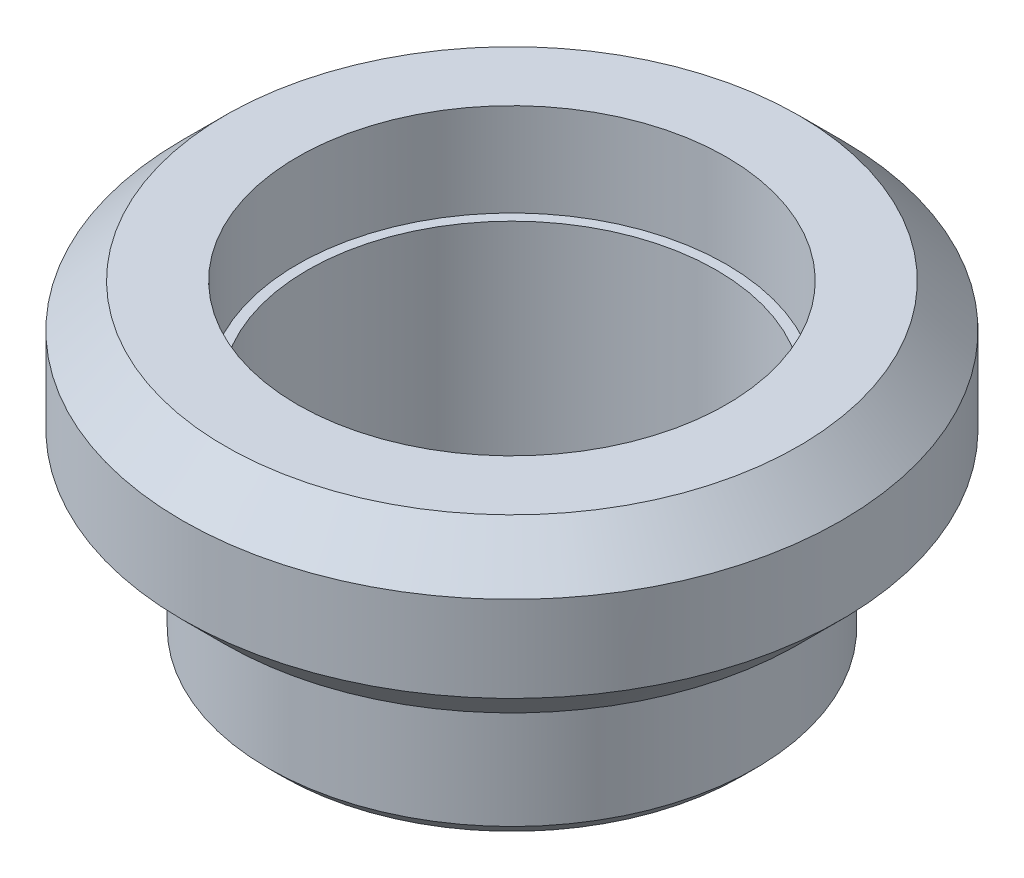
from build123d import *

# Parameters (mm, degrees)
CHAMFER1_SIZE = 3
CHAMFER2_SIZE = 1


with BuildPart() as part:
    # Sketch1 → Revolve1 (revolve)
    with BuildSketch(Plane.XY):
        Polygon((14.3, 0), (17.05, 0), (17.05, 10), (23.05, 10), (23.05, 22), (15, 22), (15, 15.5), (14.3, 15.5), align=None)
    revolve(axis=Axis((0, 23.1, 0), (0, -1, 0)))

    # Chamfer1
    chamfer1_edges = [part.edges().sort_by_distance(p)[0] for p in [
        (-23.05, 22, 0),
        (-23.05, 10, 0),
    ]]
    chamfer(chamfer1_edges, length=CHAMFER1_SIZE)

    # Chamfer2
    chamfer2_edges = [part.edges().sort_by_distance(p)[0] for p in [
        (-17.05, 0, 0),
    ]]
    chamfer(chamfer2_edges, length=CHAMFER2_SIZE)


solid = part.part
